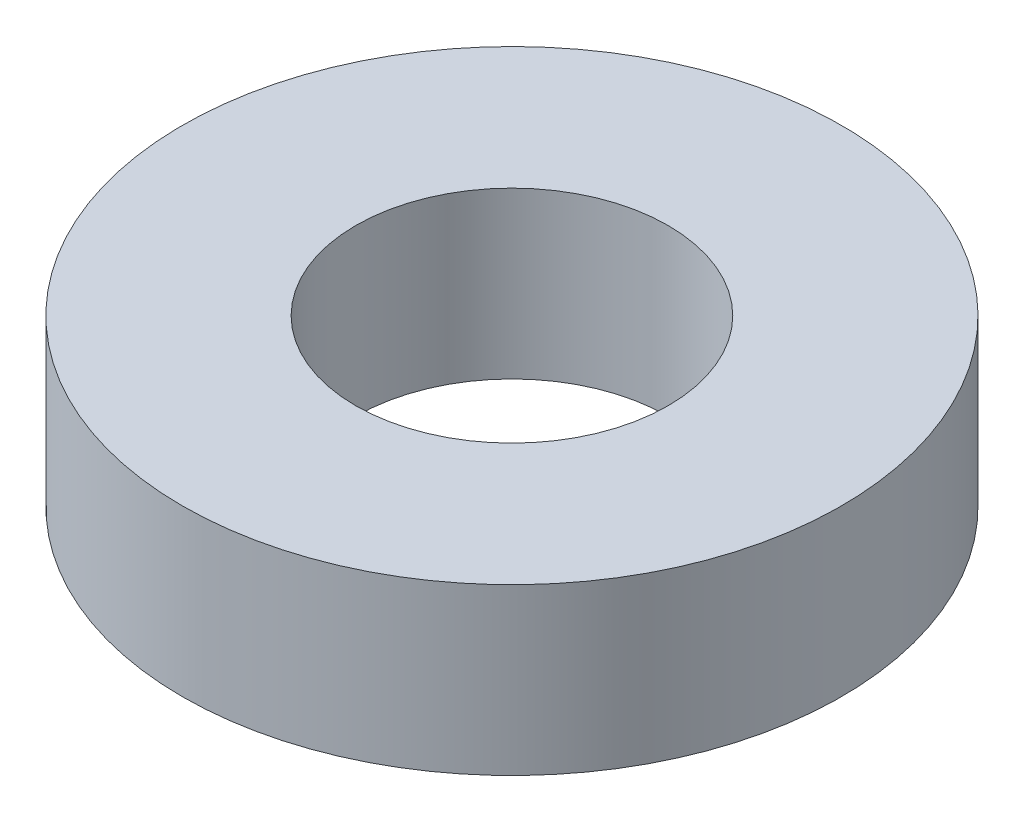
from build123d import *

# Parameters (mm, degrees)
SKETCH1_R                    = 3.165671037
M3_NYLON_WASHER_DEPTH        = 1.5875
F_3_0_3_DIAMETER_HOLE1_D     = 3
F_3_0_3_DIAMETER_HOLE1_DEPTH = 25.4
F_3_0_3_DIAMETER_HOLE1_TIP   = 0.901290929


with BuildPart() as part:
    # Sketch1 → M3 nylon washer (new body)
    with BuildSketch(Plane(origin=(0, 0, 0), x_dir=(1, 0, 0), z_dir=(0, 1, 0))):
        with Locations((4.263602365, -12.605433078)):
            Circle(SKETCH1_R)
    extrude(amount=M3_NYLON_WASHER_DEPTH)

    # Ø3.0 (3) Diameter Hole1
    with Locations(Plane(origin=(0, 1.5875, 0), x_dir=(-1, 0, 0), z_dir=(0, 1, 0))):
        with Locations((-4.263602365, 12.605433078)):
            Hole(F_3_0_3_DIAMETER_HOLE1_D / 2, depth=F_3_0_3_DIAMETER_HOLE1_DEPTH)
            with Locations((0, 0, -(F_3_0_3_DIAMETER_HOLE1_DEPTH + F_3_0_3_DIAMETER_HOLE1_TIP / 2))):  # 118° drill point
                Cone(0, F_3_0_3_DIAMETER_HOLE1_D / 2, F_3_0_3_DIAMETER_HOLE1_TIP, mode=Mode.SUBTRACT)


solid = part.part
